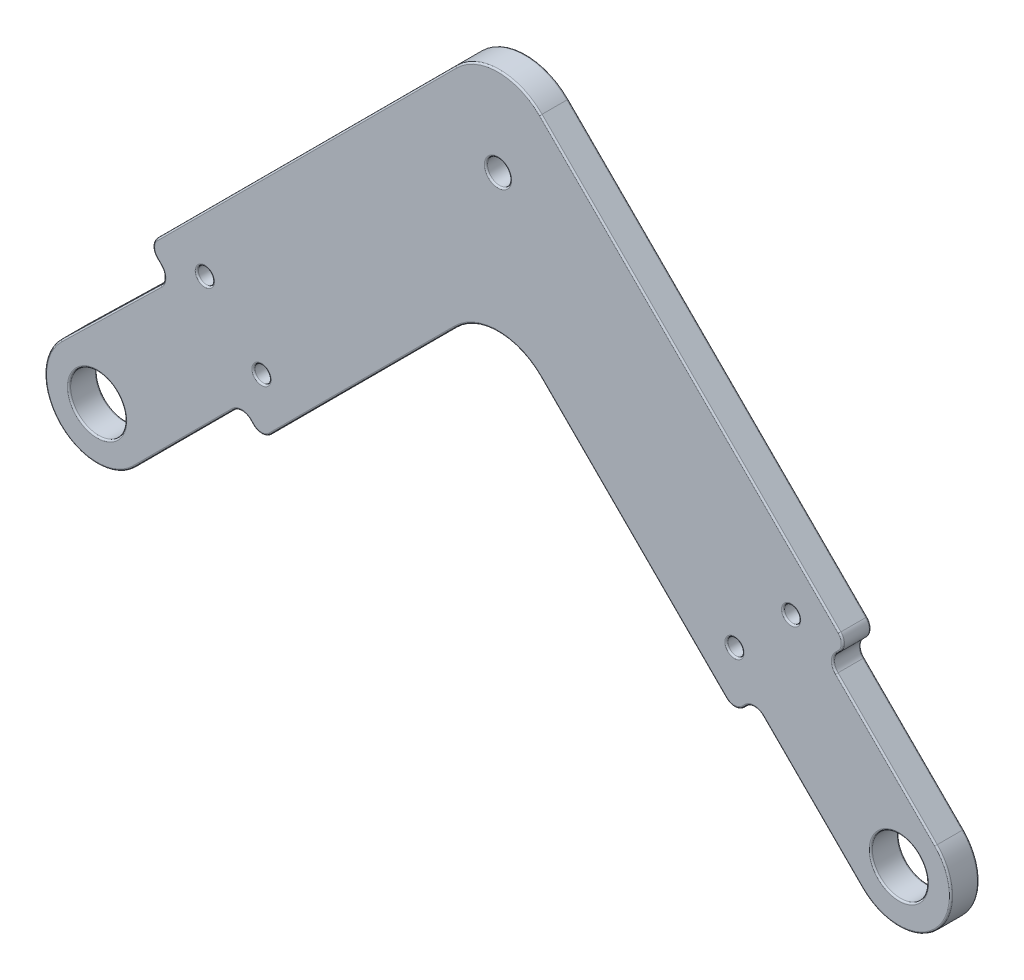
from build123d import *

# Parameters (mm, degrees)
SKETCH6_R           = 3.5
SKETCH6_R_2         = 1
SKETCH6_R_3         = 1.5
BOSS_EXTRUDE1_DEPTH = 3.5
FILLET1_R           = 7.5
FILLET2_R           = 1.5
FILLET3_R           = 0.2


with BuildPart() as part:
    # Sketch6 → Boss-Extrude1 (new body)
    with BuildSketch(Plane.XY):
        with BuildLine():
            Line((-95.403805922, -4.596194078), (-81.96877708, 8.838834765))
            Line((-81.96877708, 8.838834765), (-79.493903346, 6.363961031))
            Line((-79.493903346, 6.363961031), (-50, 35.857864376))
            Line((-50, 35.857864376), (-20.506096654, 6.363961031))
            Line((-20.506096654, 6.363961031), (-18.03122292, 8.838834765))
            Line((-18.03122292, 8.838834765), (-4.596194078, -4.596194078))
            ThreePointArc((-4.596194078, -4.596194078), (4.596194078, -4.596194078), (4.596194078, 4.596194078))
            Line((4.596194078, 4.596194078), (-8.838834765, 18.03122292))
            Line((-8.838834765, 18.03122292), (-6.363961031, 20.506096654))
            Line((-6.363961031, 20.506096654), (-50, 64.142135624))
            Line((-50, 64.142135624), (-93.636038969, 20.506096654))
            Line((-93.636038969, 20.506096654), (-90.980851591, 17.850909276))
            Line((-90.980851591, 17.850909276), (-104.533955357, 4.657601188))
            ThreePointArc((-104.533955357, 4.657601188), (-104.627002282, -4.565177968), (-95.403805922, -4.596194078))
        make_face()
        Circle(SKETCH6_R, mode=Mode.SUBTRACT)
        with Locations((-100, 0)):
            Circle(SKETCH6_R, mode=Mode.SUBTRACT)
        with Locations((-20.506096654, 13.435028843)):
            Circle(SKETCH6_R_2, mode=Mode.SUBTRACT)
        with Locations((-79.493903346, 13.435028843)):
            Circle(SKETCH6_R_2, mode=Mode.SUBTRACT)
        with Locations((-86.564971157, 20.506096654)):
            Circle(SKETCH6_R_2, mode=Mode.SUBTRACT)
        with Locations((-50, 50)):
            Circle(SKETCH6_R_3, mode=Mode.SUBTRACT)
        with Locations((-13.435028843, 20.506096654)):
            Circle(SKETCH6_R_2, mode=Mode.SUBTRACT)
    extrude(amount=BOSS_EXTRUDE1_DEPTH)

    # Fillet1
    fillet1_edges = [part.edges().sort_by_distance(p)[0] for p in [
        (-50, 64.142135624, 1.75),
        (-50, 35.857864376, 1.75),
    ]]
    fillet(fillet1_edges, radius=FILLET1_R)

    # Fillet2
    fillet2_edges = [part.edges().sort_by_distance(p)[0] for p in [
        (-81.96877708, 8.838834765, 1.75),
        (-90.980851591, 17.850909276, 1.75),
        (-93.636038969, 20.506096654, 1.75),
        (-6.363961031, 20.506096654, 1.75),
        (-8.838834765, 18.03122292, 1.75),
        (-18.03122292, 8.838834765, 1.75),
        (-20.506096654, 6.363961031, 1.75),
        (-79.493903346, 6.363961031, 1.75),
    ]]
    fillet(fillet2_edges, radius=FILLET2_R)

    # Fillet3
    fillet3_edges = [part.edges().sort_by_distance(p)[0] for p in [
        (-79.493903346, 6.985281374, 3.5),
        (-93.014718626, 20.506096654, 3.5),
        (-91.616569941, 17.855184959, 0),
        (-91.616569941, 17.855184959, 3.5),
        (-81.96877708, 8.217514421, 0),
        (-81.96877708, 8.217514421, 3.5),
        (-8.217514421, 18.03122292, 0),
        (-8.217514421, 18.03122292, 3.5),
        (-18.03122292, 8.217514421, 0),
        (-18.03122292, 8.217514421, 3.5),
        (-89.216621587, 1.590990258, 0),
        (-104.627002282, -4.565177968, 0),
        (-1.590990258, 10.783378413, 0),
        (4.596194078, -4.596194078, 0),
        (4.596194078, -4.596194078, 3.5),
        (-1.590990258, 10.783378413, 3.5),
        (-3.5, 0, 0),
        (-3.5, 0, 3.5),
        (-103.5, 0, 0),
        (-103.5, 0, 3.5),
        (-21.506096654, 13.435028843, 0),
        (-21.506096654, 13.435028843, 3.5),
        (-80.493903346, 13.435028843, 0),
        (-80.493903346, 13.435028843, 3.5),
        (-87.564971157, 20.506096654, 0),
        (-87.564971157, 20.506096654, 3.5),
        (-104.627002282, -4.565177968, 3.5),
        (-51.5, 50, 0),
        (-51.5, 50, 3.5),
        (-89.216621587, 1.590990258, 3.5),
        (-14.435028843, 20.506096654, 0),
        (-14.435028843, 20.506096654, 3.5),
        (-33.131727984, 18.98959236, 0),
        (-33.131727984, 18.98959236, 3.5),
        (-73.939339828, 40.202795796, 0),
        (-73.939339828, 40.202795796, 3.5),
        (-50, 61.035533906, 0),
        (-50, 61.035533906, 3.5),
        (-50, 32.751262658, 0),
        (-50, 32.751262658, 3.5),
        (-92.315627321, 19.185685006, 0),
        (-92.315627321, 19.185685006, 3.5),
        (-26.060660172, 40.202795796, 0),
        (-7.601397898, 19.268659787, 0),
        (-10.783378413, 1.590990258, 0),
        (-19.268659787, 7.601397898, 0),
        (-66.868272016, 18.98959236, 0),
        (-80.731340213, 7.601397898, 0),
        (-98.302096991, 10.724021751, 0),
        (-20.506096654, 6.985281374, 0),
        (-6.985281374, 20.506096654, 0),
        (-79.493903346, 6.985281374, 0),
        (-93.014718626, 20.506096654, 0),
        (-26.060660172, 40.202795796, 3.5),
        (-98.302096991, 10.724021751, 3.5),
        (-80.731340213, 7.601397898, 3.5),
        (-66.868272016, 18.98959236, 3.5),
        (-19.268659787, 7.601397898, 3.5),
        (-10.783378413, 1.590990258, 3.5),
        (-7.601397898, 19.268659787, 3.5),
        (-20.506096654, 6.985281374, 3.5),
        (-6.985281374, 20.506096654, 3.5),
    ]]
    fillet(fillet3_edges, radius=FILLET3_R)


solid = part.part
